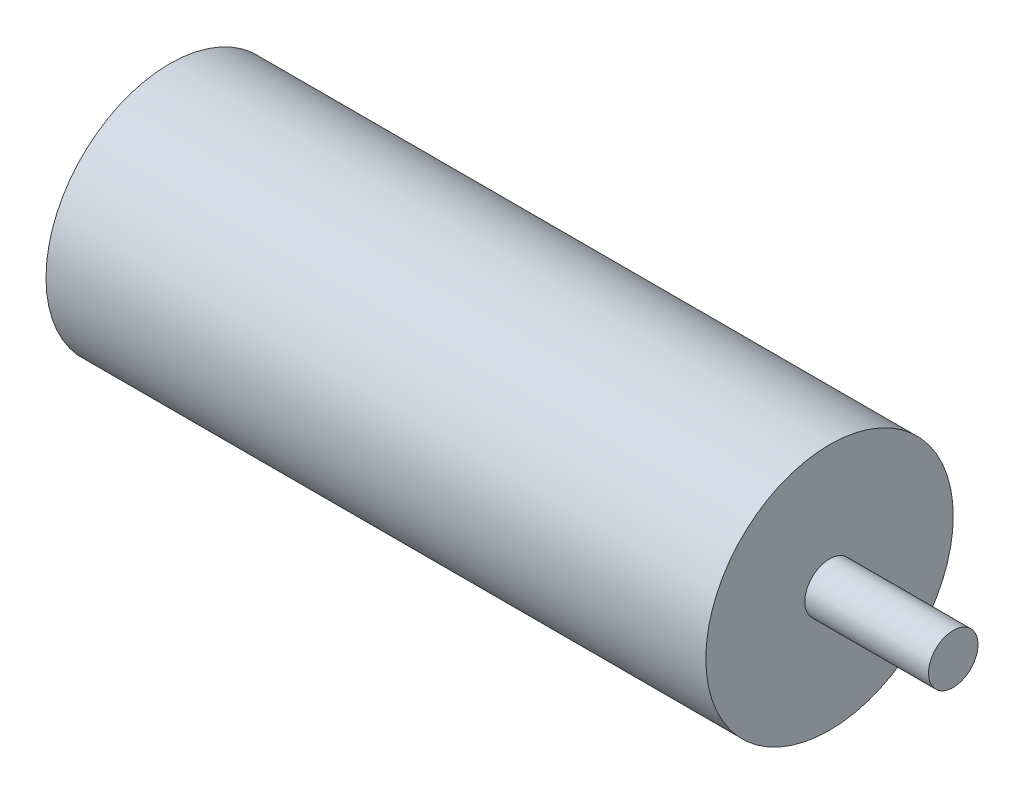
from build123d import *

# Parameters (mm, degrees)
SKETCH1_R           = 7.5
BOSS_EXTRUDE1_DEPTH = 45
SKETCH2_R           = 1.5
BOSS_EXTRUDE2_DEPTH = 15
SKETCH3_R           = 19.310171954
CUT_EXTRUDE1_DEPTH  = 5
SKETCH4_R           = 8.741086828
CUT_EXTRUDE2_DEPTH  = 7.5


with BuildPart() as part:
    # Sketch1 → Boss-Extrude1 (new body)
    with BuildSketch(Plane(origin=(0, 0, 0), x_dir=(0, 0, -1), z_dir=(1, 0, 0))):
        with Locations((-35.817726835, 20.099436521)):
            Circle(SKETCH1_R)
    extrude(amount=BOSS_EXTRUDE1_DEPTH)

    # Sketch2 → Boss-Extrude2 (add)
    with BuildSketch(Plane(origin=(45, 0, 0), x_dir=(0, 0, -1), z_dir=(1, 0, 0))):
        with Locations((-35.817726835, 20.099436521)):
            Circle(SKETCH2_R)
    extrude(amount=BOSS_EXTRUDE2_DEPTH)

    # Sketch3 → Cut-Extrude1 (cut)
    with BuildSketch(Plane.ZY):
        with Locations((35.946372141, 19.473767111)):
            Circle(SKETCH3_R)
    extrude(amount=-CUT_EXTRUDE1_DEPTH, mode=Mode.SUBTRACT)

    # Sketch4 → Cut-Extrude2 (cut)
    with BuildSketch(Plane(origin=(60, 0, 0), x_dir=(0, 0, -1), z_dir=(1, 0, 0))):
        with Locations((-35.844588169, 20.10752339)):
            Circle(SKETCH4_R)
    extrude(amount=-CUT_EXTRUDE2_DEPTH, mode=Mode.SUBTRACT)


solid = part.part
